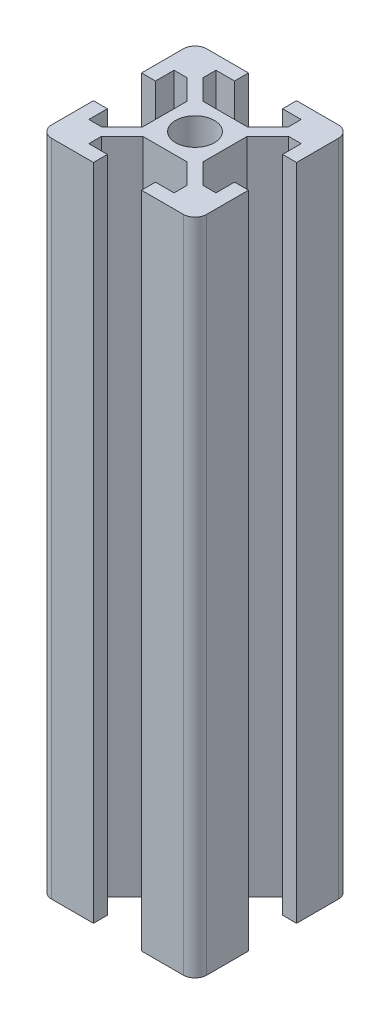
from build123d import *

# Parameters (mm, degrees)
DODANIE_WYCI_GNI_CIE1_DEPTH = 85


with BuildPart() as part:
    # Szkic1 → Dodanie-wyciągnięcie1 (new body)
    with BuildSketch(Plane(origin=(0, 0, 0), x_dir=(1, 0, 0), z_dir=(0, 1, 0))):
        with BuildLine():
            Line((0, 3.9), (2.839339828, 3.9))
            Line((2.839339828, 3.9), (5.5, 6.560660172))
            Line((5.5, 6.560660172), (5.5, 8.2))
            Line((5.5, 8.2), (3.1, 8.2))
            Line((3.1, 8.2), (3.1, 10))
            Line((3.1, 10), (8.5, 10))
            ThreePointArc((8.5, 10), (9.560660172, 9.560660172), (10, 8.5))
            Line((10, 8.5), (10, 3.1))
            Line((10, 3.1), (8.2, 3.1))
            Line((8.2, 3.1), (8.2, 5.5))
            Line((8.2, 5.5), (6.560660172, 5.5))
            Line((6.560660172, 5.5), (3.9, 2.839339828))
            Line((3.9, 2.839339828), (3.9, 0))
            Line((3.9, 0), (3.9, -2.839339828))
            Line((3.9, -2.839339828), (6.560660172, -5.5))
            Line((6.560660172, -5.5), (8.2, -5.5))
            Line((8.2, -5.5), (8.2, -3.1))
            Line((8.2, -3.1), (10, -3.1))
            Line((10, -3.1), (10, -8.5))
            ThreePointArc((10, -8.5), (9.560660172, -9.560660172), (8.5, -10))
            Line((8.5, -10), (3.1, -10))
            Line((3.1, -10), (3.1, -8.2))
            Line((3.1, -8.2), (5.5, -8.2))
            Line((5.5, -8.2), (5.5, -6.560660172))
            Line((5.5, -6.560660172), (2.839339828, -3.9))
            Line((2.839339828, -3.9), (0, -3.9))
            Line((0, -3.9), (-2.839339828, -3.9))
            Line((-2.839339828, -3.9), (-5.5, -6.560660172))
            Line((-5.5, -6.560660172), (-5.5, -8.2))
            Line((-5.5, -8.2), (-3.1, -8.2))
            Line((-3.1, -8.2), (-3.1, -10))
            Line((-3.1, -10), (-8.5, -10))
            ThreePointArc((-8.5, -10), (-9.560660172, -9.560660172), (-10, -8.5))
            Line((-10, -8.5), (-10, -3.1))
            Line((-10, -3.1), (-8.2, -3.1))
            Line((-8.2, -3.1), (-8.2, -5.5))
            Line((-8.2, -5.5), (-6.560660172, -5.5))
            Line((-6.560660172, -5.5), (-3.9, -2.839339828))
            Line((-3.9, -2.839339828), (-3.9, 0))
            Line((-3.9, 0), (-3.9, 2.839339828))
            Line((-3.9, 2.839339828), (-6.560660172, 5.5))
            Line((-6.560660172, 5.5), (-8.2, 5.5))
            Line((-8.2, 5.5), (-8.2, 3.1))
            Line((-8.2, 3.1), (-10, 3.1))
            Line((-10, 3.1), (-10, 8.5))
            ThreePointArc((-10, 8.5), (-9.560660172, 9.560660172), (-8.5, 10))
            Line((-8.5, 10), (-3.1, 10))
            Line((-3.1, 10), (-3.1, 8.2))
            Line((-3.1, 8.2), (-5.5, 8.2))
            Line((-5.5, 8.2), (-5.5, 6.560660172))
            Line((-5.5, 6.560660172), (-2.839339828, 3.9))
            Line((-2.839339828, 3.9), (0, 3.9))
        make_face()
        with BuildLine():
            ThreePointArc((2.5, 0), (1.767766953, 1.767766953), (0, 2.5))
            ThreePointArc((0, 2.5), (-1.767766953, 1.767766953), (-2.5, 0))
            ThreePointArc((-2.5, 0), (-1.767766953, -1.767766953), (0, -2.5))
            ThreePointArc((0, -2.5), (1.767766953, -1.767766953), (2.5, 0))
        make_face(mode=Mode.SUBTRACT)
    extrude(amount=DODANIE_WYCI_GNI_CIE1_DEPTH)


solid = part.part
